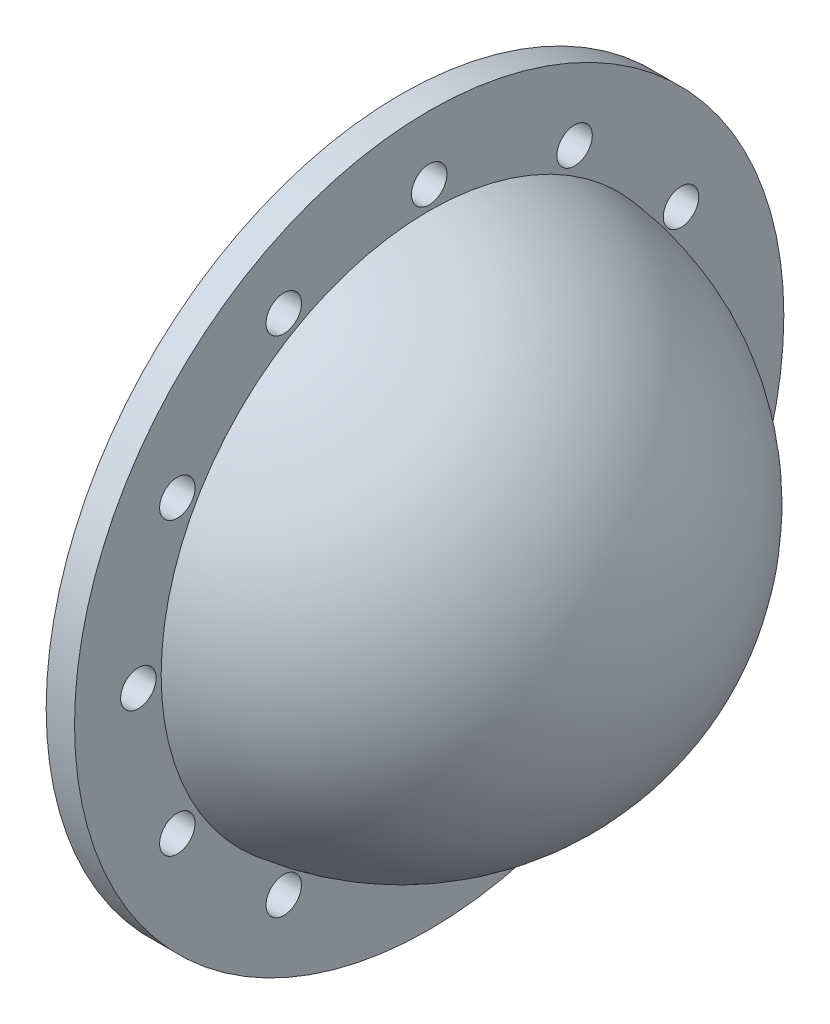
from build123d import *

# Parameters (mm, degrees)
SKETCH1_R           = 2500
SKETCH1_R_2         = 125
BOSS_EXTRUDE1_DEPTH = 200
SKETCH2_R           = 1800
CUT_EXTRUDE1_DEPTH  = 3542.186241925
REVOLVE1_ANGLE      = 180


with BuildPart() as part:
    # Sketch1 → Boss-Extrude1 (new body)
    with BuildSketch(Plane(origin=(0, 0, 0), x_dir=(0, 0, -1), z_dir=(1, 0, 0))):
        Circle(SKETCH1_R)
        with Locations((-1025, -1775.352077758)):
            Circle(SKETCH1_R_2, mode=Mode.SUBTRACT)
        with Locations((-1775.352077758, -1025)):
            Circle(SKETCH1_R_2, mode=Mode.SUBTRACT)
        with Locations((-2050, 0)):
            Circle(SKETCH1_R_2, mode=Mode.SUBTRACT)
        with Locations((0, -2050)):
            Circle(SKETCH1_R_2, mode=Mode.SUBTRACT)
        with Locations((1025, -1775.352077758)):
            Circle(SKETCH1_R_2, mode=Mode.SUBTRACT)
        with Locations((1775.352077758, -1025)):
            Circle(SKETCH1_R_2, mode=Mode.SUBTRACT)
        with Locations((-1775.352077758, 1025)):
            Circle(SKETCH1_R_2, mode=Mode.SUBTRACT)
        with Locations((-1025, 1775.352077758)):
            Circle(SKETCH1_R_2, mode=Mode.SUBTRACT)
        with Locations((2050, 0)):
            Circle(SKETCH1_R_2, mode=Mode.SUBTRACT)
        with Locations((1775.352077758, 1025)):
            Circle(SKETCH1_R_2, mode=Mode.SUBTRACT)
        with Locations((1025, 1775.352077758)):
            Circle(SKETCH1_R_2, mode=Mode.SUBTRACT)
        with Locations((0, 2050)):
            Circle(SKETCH1_R_2, mode=Mode.SUBTRACT)
    extrude(amount=BOSS_EXTRUDE1_DEPTH)

    # Sketch2 → Cut-Extrude1 (cut, through all)
    with BuildSketch(Plane.ZY):
        Circle(SKETCH2_R)
    extrude(amount=-CUT_EXTRUDE1_DEPTH, mode=Mode.SUBTRACT)

    # Sketch4 → Revolve1 (revolve)
    with BuildSketch(Plane.ZY):
        with BuildLine():
            Line((0, 1800), (0, 1900))
            ThreePointArc((0, 1900), (1900, 0), (0, -1900))
            Line((0, -1900), (0, -1800))
            ThreePointArc((0, -1800), (1800, 0), (0, 1800))
        make_face()
    revolve(axis=Axis((0, -1900, 0), (0, 1, 0)), revolution_arc=REVOLVE1_ANGLE)


solid = part.part
